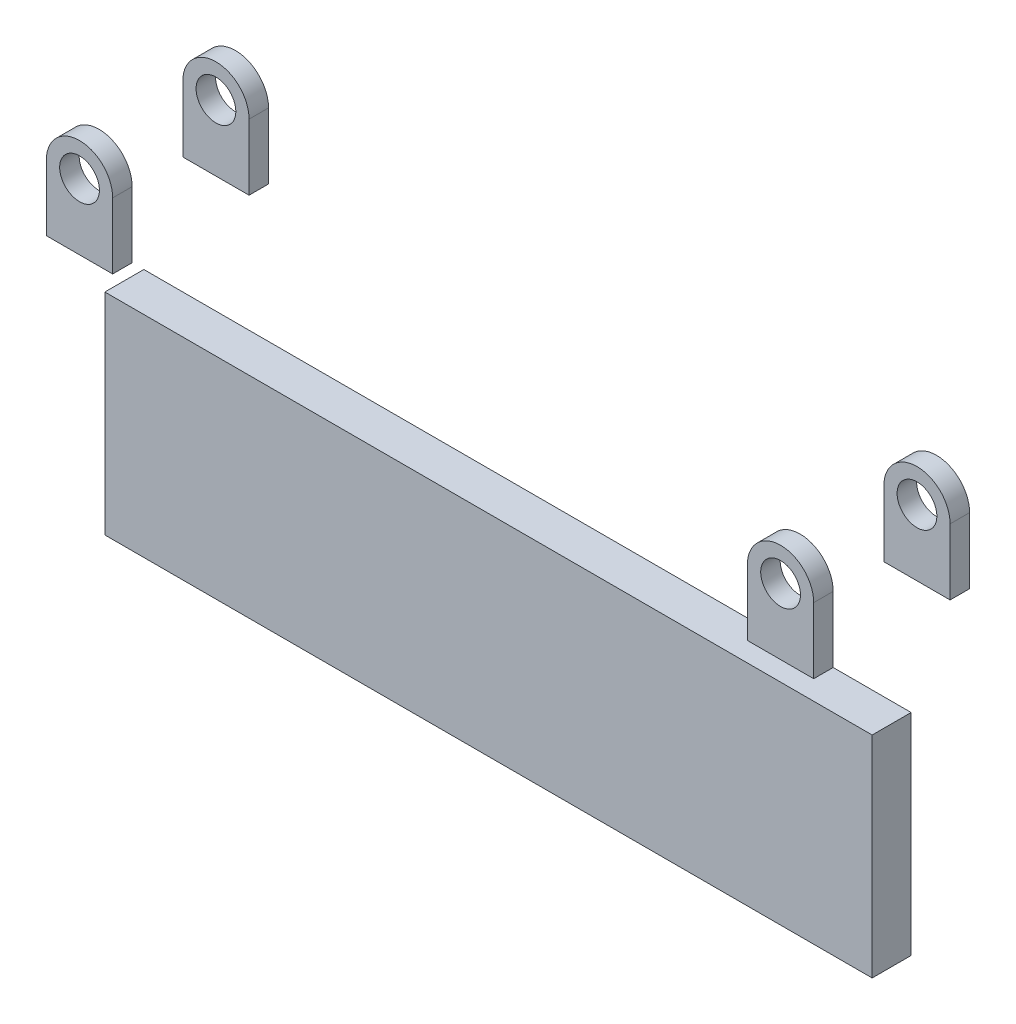
from build123d import *

# Parameters (mm, degrees)
SKETCH2_R             = 6.477
BOSS_EXTRUDE1_DEPTH   = 50.8
BOSS_EXTRUDE1_2_DEPTH = 50.8
SKETCH6_W             = 38.1
SKETCH6_H             = 36.341758233
CUT_EXTRUDE2_DEPTH    = 267.208
SKETCH9_W             = 250.0376
SKETCH9_H             = 12.7
BOSS_EXTRUDE2_DEPTH   = 93.98
SKETCH10_W            = 250.0376
SKETCH10_H            = 12.7
CUT_EXTRUDE3_DEPTH    = 25.4


with BuildPart() as part:
    # Sketch2 → Boss-Extrude1 (new body)
    with BuildSketch(Plane.XY):
        with BuildLine():
            Line((-10.795, 0), (-10.795, -21.477155865))
            Line((-10.795, -21.477155865), (10.795, -21.477155865))
            Line((10.795, -21.477155865), (10.795, 0))
            ThreePointArc((10.795, 0), (0, 10.795), (-10.795, 0))
        make_face()
        Circle(SKETCH2_R, mode=Mode.SUBTRACT)
    extrude(amount=BOSS_EXTRUDE1_DEPTH)


with BuildPart() as body_2:
    # Sketch2 → Boss-Extrude1 2 (new body)
    with BuildSketch(Plane.XY):
        with BuildLine():
            Line((217.6526, 0), (217.6526, -21.477155865))
            Line((217.6526, -21.477155865), (239.2426, -21.477155865))
            Line((239.2426, -21.477155865), (239.2426, 0))
            ThreePointArc((239.2426, 0), (228.4476, 10.795), (217.6526, 0))
        make_face()
        with Locations((228.4476, 0)):
            Circle(SKETCH2_R, mode=Mode.SUBTRACT)
    extrude(amount=BOSS_EXTRUDE1_2_DEPTH)


with BuildPart() as cut_extrude2_tool:
    # Sketch6 → Cut-Extrude2 (new body)
    with BuildSketch(Plane(origin=(239.2426, 0, 0), x_dir=(0, 0, -1), z_dir=(1, 0, 0))):
        with Locations((-25.4, -3.306276748)):
            Rectangle(SKETCH6_W, SKETCH6_H)
    extrude(amount=-CUT_EXTRUDE2_DEPTH)


with BuildPart() as part_1:
    add(part.part)

    # Cut-Extrude2: cut by cut_extrude2_tool
    add(cut_extrude2_tool.part, mode=Mode.SUBTRACT)


with BuildPart() as body_2_1:
    add(body_2.part)

    # Cut-Extrude2: cut by cut_extrude2_tool
    add(cut_extrude2_tool.part, mode=Mode.SUBTRACT)


with BuildPart() as body_3:
    # Sketch9 → Boss-Extrude2 (new body)
    with BuildSketch(Plane.XZ.offset(21.477155865)):
        with Locations((114.2238, 25.4)):
            Rectangle(SKETCH9_W, SKETCH9_H)
    extrude(amount=BOSS_EXTRUDE2_DEPTH)

    # Sketch10 → Cut-Extrude3 (cut)
    with BuildSketch(Plane(origin=(0, -21.477155865, 0), x_dir=(1, 0, 0), z_dir=(0, 1, 0))):
        with Locations((114.2238, -25.4)):
            Rectangle(SKETCH10_W, SKETCH10_H)
    extrude(amount=-CUT_EXTRUDE3_DEPTH, mode=Mode.SUBTRACT)


solid = Compound([part_1.part, body_2_1.part, body_3.part])
